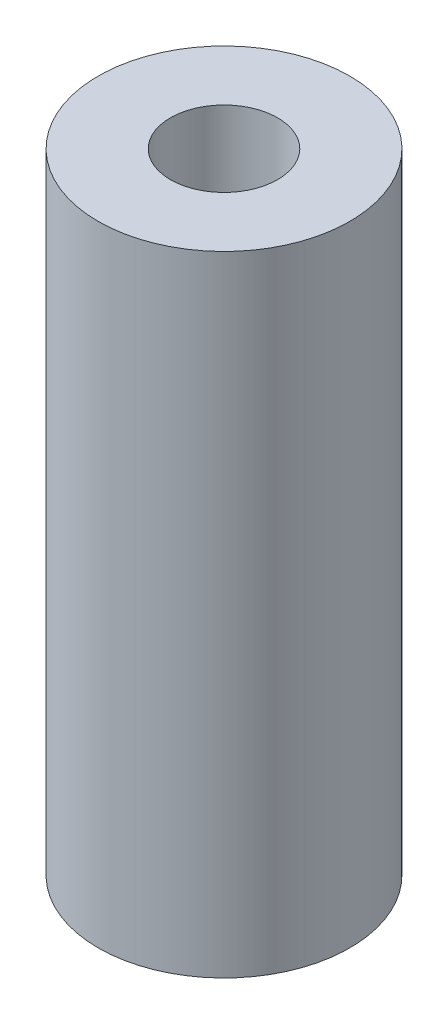
from build123d import *

# Parameters (mm, degrees)
SKETCH1_R                 = 3.175
BOSS_EXTRUDE1_DEPTH       = 15.875
TAP_DRILL_FOR_6_32_TAP1_D = 2.7051


with BuildPart() as part:
    # Sketch1 → Boss-Extrude1 (new body)
    with BuildSketch(Plane(origin=(0, 0, 0), x_dir=(1, 0, 0), z_dir=(0, 1, 0))):
        Circle(SKETCH1_R)
    extrude(amount=BOSS_EXTRUDE1_DEPTH)

    # Tap Drill for #6-32 Tap1 (through all)
    with Locations(Plane(origin=(0, 15.875, 0), x_dir=(1, 0, 0), z_dir=(0, 1, 0))):
        with Locations((0, 0)):
            Hole(TAP_DRILL_FOR_6_32_TAP1_D / 2)


solid = part.part
